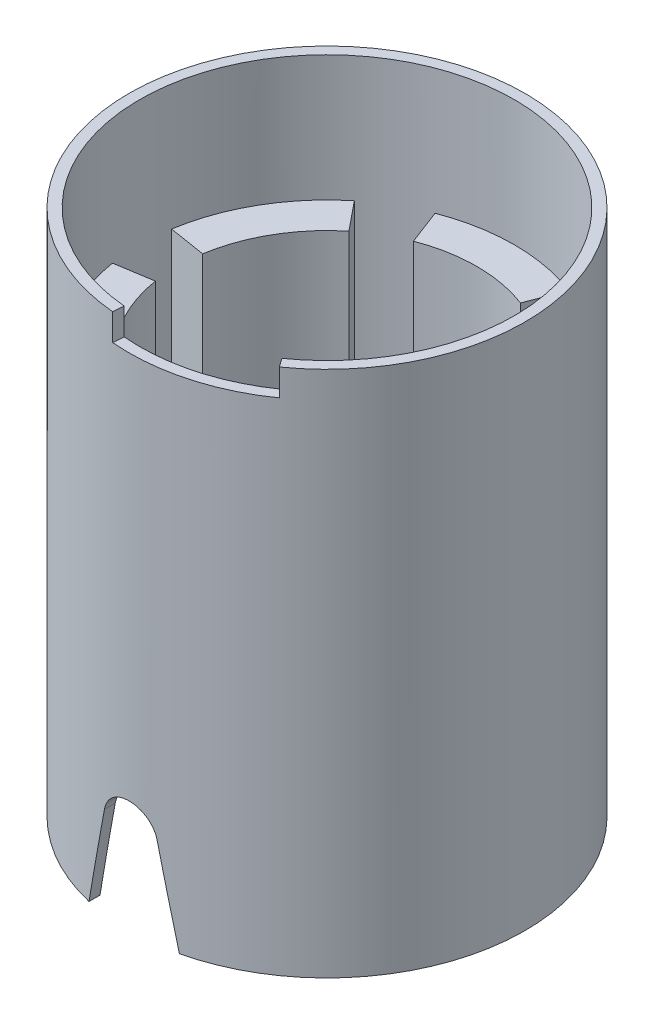
from build123d import *

# Parameters (mm, degrees)
SKETCH1_R           = 37
SKETCH1_R_2         = 35
BOSS_EXTRUDE1_DEPTH = 98.5
CUT_EXTRUDE2_REACH  = 76
CUT_EXTRUDE3_DEPTH  = 5
BOSS_EXTRUDE2_DEPTH = 42
CIRPATTERN1_COUNT   = 6


with BuildPart() as part:
    # Sketch1 → Boss-Extrude1 (new body)
    with BuildSketch(Plane(origin=(0, 0, 0), x_dir=(1, 0, 0), z_dir=(0, 1, 0))):
        Circle(SKETCH1_R)
        Circle(SKETCH1_R_2, mode=Mode.SUBTRACT)
    extrude(amount=BOSS_EXTRUDE1_DEPTH)

    # Sketch2 → Cut-Extrude2 (cut, up to next)
    with BuildSketch(Plane.XY.offset(37), mode=Mode.PRIVATE) as cut_extrude2_sk1:
        with BuildLine():
            Line((-8.45, 0), (-4.916814722, 17))
            ThreePointArc((-4.916814722, 17), (0, 21), (4.916814722, 17))
            Line((4.916814722, 17), (8.45, 0))
            Line((8.45, 0), (-8.45, 0))
        make_face()
    cut_extrude2_tool1 = extrude(cut_extrude2_sk1.sketch, amount=-CUT_EXTRUDE2_REACH, mode=Mode.PRIVATE) & part.part
    add(cut_extrude2_tool1.solids().sort_by_distance((0, 9.002939, 37))[0], mode=Mode.SUBTRACT)

    # Sketch4 → Cut-Extrude3 (cut)
    with BuildSketch(Plane(origin=(0, 98.5, 0), x_dir=(1, 0, 0), z_dir=(0, 1, 0))):
        with BuildLine():
            Line((20.172972973, -28.601593687), (21.325714286, -30.235970469))
            ThreePointArc((21.325714286, -30.235970469), (9.649317719, -35.719611806), (-3.2, -36.861361885))
            Line((-3.2, -36.861361885), (-3.027027027, -34.868855837))
            ThreePointArc((-3.027027027, -34.868855837), (9.127732978, -33.788821978), (20.172972973, -28.601593687))
        make_face()
    extrude(amount=-CUT_EXTRUDE3_DEPTH, mode=Mode.SUBTRACT)

    # Sketch5 → Boss-Extrude2 (add)
    with BuildSketch(Plane(origin=(0, 33, 0), x_dir=(1, 0, 0), z_dir=(0, 1, 0))):
        with BuildLine():
            Line((-12.5, -32.691742077), (-10, -26.153393661))
            ThreePointArc((-10, -26.153393661), (0, -28), (10, -26.153393661))
            Line((10, -26.153393661), (12.5, -32.691742077))
            ThreePointArc((12.5, -32.691742077), (0, -35), (-12.5, -32.691742077))
        make_face()
    boss_extrude2 = extrude(amount=BOSS_EXTRUDE2_DEPTH)

    # CirPattern1: Boss-Extrude2 ×6 about axis
    cirpattern1_axis = Axis((0, 0, 0), (0, 1, 0))
    for i in range(1, CIRPATTERN1_COUNT):
        add(boss_extrude2.rotate(cirpattern1_axis, i * 360 / CIRPATTERN1_COUNT))


solid = part.part
